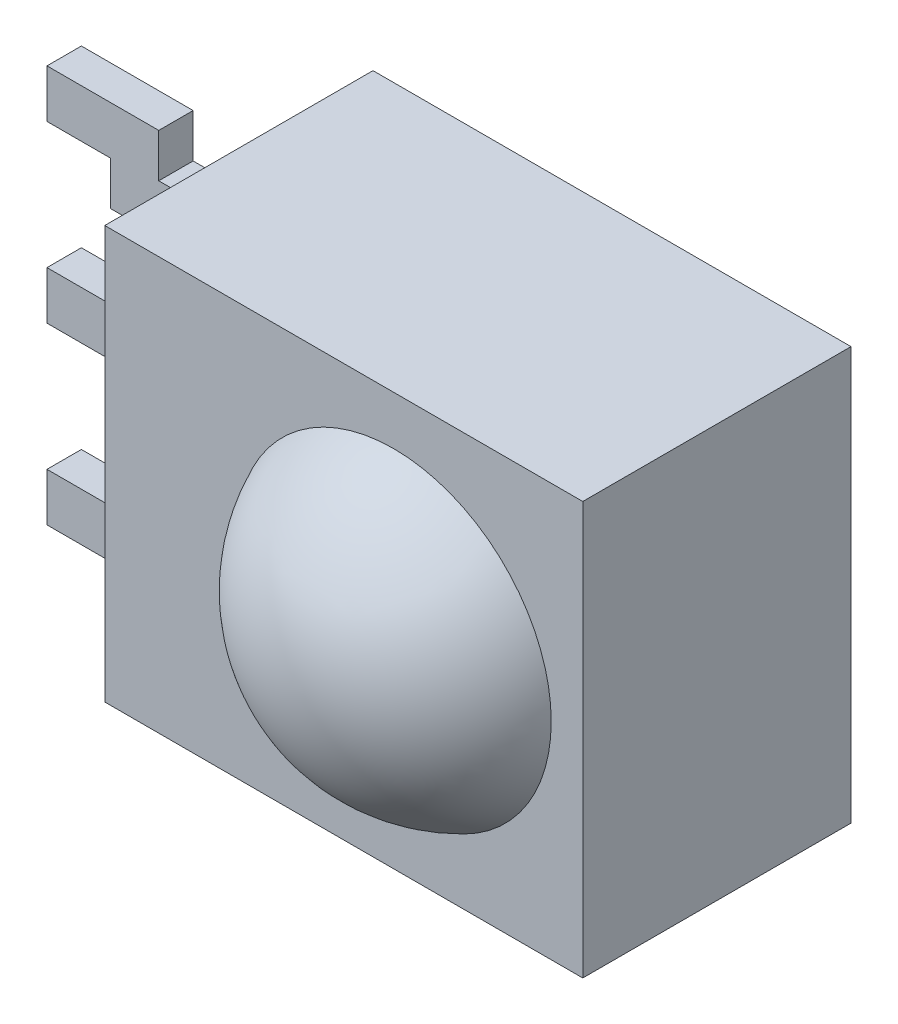
from build123d import *

# Parameters (mm, degrees)
SKETCH1_W               = 6.95
SKETCH1_H               = 6
BOSS_EXTRUDE1_DEPTH     = 1.95
SKETCH6_W               = 0.5
SKETCH6_H               = 0.7
SKETCH7_W               = 0.5
SKETCH7_H               = 0.7
BOSS_EXTRUDE3_DEPTH     = 4.7625
SKETCH8_W               = 0.5
SKETCH8_H               = 0.7
SKETCH11_W              = 0.5
SKETCH11_H              = 0.7
BOSS_EXTRUDE4_DEPTH     = 2.54
CUT_EXTRUDE1_DEPTH      = 4.2
CUT_EXTRUDE1_DEPTH_BACK = 4.04


with BuildPart() as part:
    # Sketch1 → Boss-Extrude1 (new body, symmetric)
    with BuildSketch(Plane.XY):
        Rectangle(SKETCH1_W, SKETCH1_H)
    extrude(amount=BOSS_EXTRUDE1_DEPTH, both=True)

    # Sketch4 → Revolve6 (revolve)
    with BuildSketch(Plane(origin=(0, 0, 0), x_dir=(1, 0, 0), z_dir=(0, 1, 0))):
        with BuildLine():
            Line((-1.566287847, -1.95), (0.725, -1.95))
            Line((0.725, -1.95), (0.725, -3.45))
            ThreePointArc((0.725, -3.45), (-0.644306394, -3.041650066), (-1.566287847, -1.95))
        make_face()
    revolve(axis=Axis((0.725, 0, 1.95), (0, 0, 1)))


with BuildPart() as body_2:
    # Sweep2: sweep along a path in Sketch5
    with BuildLine(Plane.XY) as sweep2_path:
        Line((-3.475, 1.905), (-4.74, 1.905))
        Line((-4.74, 1.905), (-4.74, 2.54))
        Line((-4.74, 2.54), (-8.2375, 2.54))
    # Sketch6 → Sweep2 (sweep)
    with BuildSketch(Plane.ZY.offset(3.475)):
        with Locations((0, 1.905)):
            Rectangle(SKETCH6_W, SKETCH6_H)
    sweep(path=sweep2_path.line, transition=Transition.RIGHT)



with BuildPart() as body_3:
    # Sketch7 → Boss-Extrude3 (new body)
    with BuildSketch(Plane.ZY.offset(3.475)):
        Rectangle(SKETCH7_W, SKETCH7_H)
    extrude(amount=BOSS_EXTRUDE3_DEPTH)


with BuildPart() as body_4:
    # Sweep3: sweep along a path in Sketch10
    with BuildLine(Plane.XY) as sweep3_path:
        Line((-3.475, -1.905), (-4.74, -1.905))
        Line((-4.74, -1.905), (-4.74, -2.54))
        Line((-4.74, -2.54), (-8.2375, -2.54))
    # Sketch8 → Sweep3 (sweep)
    with BuildSketch(Plane.ZY.offset(3.475)):
        with Locations((0, -1.905)):
            Rectangle(SKETCH8_W, SKETCH8_H)
    sweep(path=sweep3_path.line, transition=Transition.RIGHT)


with BuildPart() as body_2_1:
    add(body_2.part)

    add(body_3.part)  # Boss-Extrude4 merges body 3

    add(body_4.part)  # Boss-Extrude4 merges body 4
    # Sketch11 → Boss-Extrude4 (add)
    with BuildSketch(Plane(origin=(0, 0, -0.25), x_dir=(-1, 0, 0), z_dir=(0, 0, -1))):
        with Locations((7.9875, 2.54)):
            Rectangle(SKETCH11_W, SKETCH11_H)
        with Locations((7.9875, 0)):
            Rectangle(SKETCH11_W, SKETCH11_H)
        with Locations((7.9875, -2.54)):
            Rectangle(SKETCH11_W, SKETCH11_H)
    extrude(amount=BOSS_EXTRUDE4_DEPTH)

    # Sketch12 → Cut-Extrude1 (cut, two sides)
    with BuildSketch(Plane.XY.offset(0.25)) as cut_extrude1_sk:
        Polygon((-6.015, 36.864414321), (-6.015, 3.667843), (-6.015, -3.251211746), (-6.015, -36.447783067), (-72.408142643, -36.447783067), (-72.408142643, 36.864414321), align=None)
    extrude(amount=CUT_EXTRUDE1_DEPTH, mode=Mode.SUBTRACT)
    extrude(cut_extrude1_sk.sketch, amount=-CUT_EXTRUDE1_DEPTH_BACK, mode=Mode.SUBTRACT)


solid = Compound([part.part, body_2_1.part])
